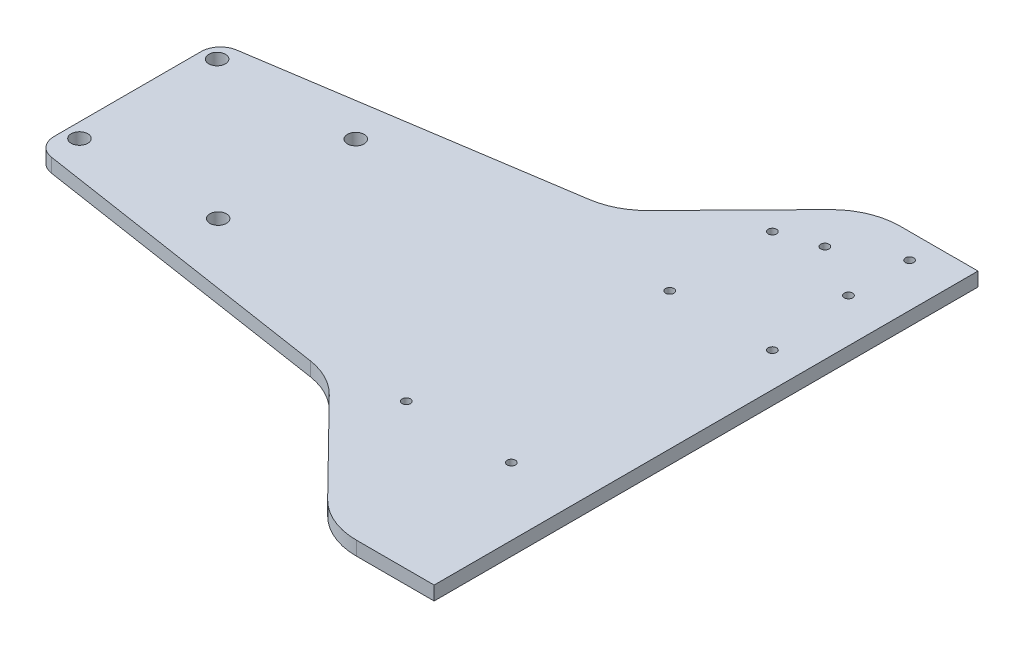
from build123d import *

# Parameters (mm, degrees)
BOSS_EXTRU_1_DEPTH      = 5
CONG_3_R                = 7
ESQUISSE3_R             = 3
ENL_V_MAT_EXTRU_1_DEPTH = 5
ESQUISSE8_R             = 1.5
ENL_V_MAT_EXTRU_5_DEPTH = 10
ESQUISSE11_R            = 1.5
ENL_V_MAT_EXTRU_7_DEPTH = 10
ESQUISSE12_W            = 8.513232075
ESQUISSE12_H            = 196.02308235
BOSS_EXTRU_2_DEPTH      = 5
ESQUISSE13_R            = 1.496707183
ESQUISSE13_R_2          = 1.50175208
ESQUISSE13_R_3          = 1.500339551
ENL_V_MAT_EXTRU_8_DEPTH = 10


with BuildPart() as part:
    # Esquisse1 → Boss.-Extru.1 (new body)
    with BuildSketch(Plane(origin=(0, 0, 0), x_dir=(1, 0, 0), z_dir=(0, 1, 0))):
        with BuildLine():
            Line((200, 98), (180.486918987, 98))
            ThreePointArc((180.486918987, 98), (170.816361757, 96.053857006), (162.651427502, 90.518425828))
            Line((162.651427502, 90.518425828), (130.227508241, 57.507666668))
            ThreePointArc((130.227508241, 57.507666668), (123.786759953, 52.773905469), (116.181163829, 50.314913559))
            Line((116.181163829, 50.314913559), (0, 32.5))
            Line((0, 32.5), (0, 19.62474242))
            Line((0, 19.62474242), (0, -19.62474242))
            Line((0, -19.62474242), (0, -32.5))
            Line((0, -32.5), (116.181163829, -50.314913559))
            ThreePointArc((116.181163829, -50.314913559), (123.786759953, -52.773905469), (130.227508241, -57.507666668))
            Line((130.227508241, -57.507666668), (162.651427502, -90.518425828))
            ThreePointArc((162.651427502, -90.518425828), (170.816361757, -96.053857006), (180.486918987, -98))
            Line((180.486918987, -98), (200, -98))
            Line((200, -98), (200, 98))
        make_face()
    extrude(amount=BOSS_EXTRU_1_DEPTH)

    # Congé3
    cong_3_edges = [part.edges().sort_by_distance(p)[0] for p in [
        (0, 2.5, 32.5),
        (0, 2.5, -32.5),
    ]]
    fillet(cong_3_edges, radius=CONG_3_R)

    # Esquisse3 → Enlèv. mat.-Extru.1 (cut)
    with BuildSketch(Plane(origin=(0, 5, 0), x_dir=(1, 0, 0), z_dir=(0, 1, 0))):
        with Locations((5.228132429, -22.542085275)):
            Circle(ESQUISSE3_R)
        with Locations((5.228132429, 27.05879269)):
            Circle(ESQUISSE3_R)
        with Locations((55.20842969, -22.542085275)):
            Circle(ESQUISSE3_R)
        with Locations((55.20842969, 27.05879269)):
            Circle(ESQUISSE3_R)
    extrude(amount=-ENL_V_MAT_EXTRU_1_DEPTH, mode=Mode.SUBTRACT)

    # Esquisse8 → Enlèv. mat.-Extru.5 (cut)
    with BuildSketch(Plane(origin=(0, 5, 0), x_dir=(1, 0, 0), z_dir=(0, 1, 0))):
        with Locations((196.148923391, 36.274574464)):
            Circle(ESQUISSE8_R)
        with Locations((159.148923391, 73.274574464)):
            Circle(ESQUISSE8_R)
        with Locations((159.148923391, 36.274574464)):
            Circle(ESQUISSE8_R)
    extrude(amount=-ENL_V_MAT_EXTRU_5_DEPTH, mode=Mode.SUBTRACT)

    # Esquisse11 → Enlèv. mat.-Extru.7 (cut)
    with BuildSketch(Plane(origin=(0, 5, 0), x_dir=(1, 0, 0), z_dir=(0, 1, 0))):
        with Locations((184.199116652, -45.869762424)):
            Circle(ESQUISSE11_R)
        with Locations((146.150097665, -45.660518454)):
            Circle(ESQUISSE11_R)
    extrude(amount=-ENL_V_MAT_EXTRU_7_DEPTH, mode=Mode.SUBTRACT)

    # Esquisse12 → Boss.-Extru.2 (add)
    with BuildSketch(Plane(origin=(0, 0, 0), x_dir=(-1, 0, 0), z_dir=(0, -1, 0))):
        with Locations((-204.256616038, 0.011541175)):
            Rectangle(ESQUISSE12_W, ESQUISSE12_H)
    extrude(amount=-BOSS_EXTRU_2_DEPTH)

    # Esquisse13 → Enlèv. mat.-Extru.8 (cut)
    with BuildSketch(Plane(origin=(0, 5, 0), x_dir=(1, 0, 0), z_dir=(0, 1, 0))):
        with Locations((192.801268115, 89.072215784)):
            Circle(ESQUISSE13_R)
        with Locations((173.269117951, 78.05884243)):
            Circle(ESQUISSE13_R_2)
        with Locations((192.801268115, 67.045469076)):
            Circle(ESQUISSE13_R_3)
    extrude(amount=-ENL_V_MAT_EXTRU_8_DEPTH, mode=Mode.SUBTRACT)


solid = part.part
